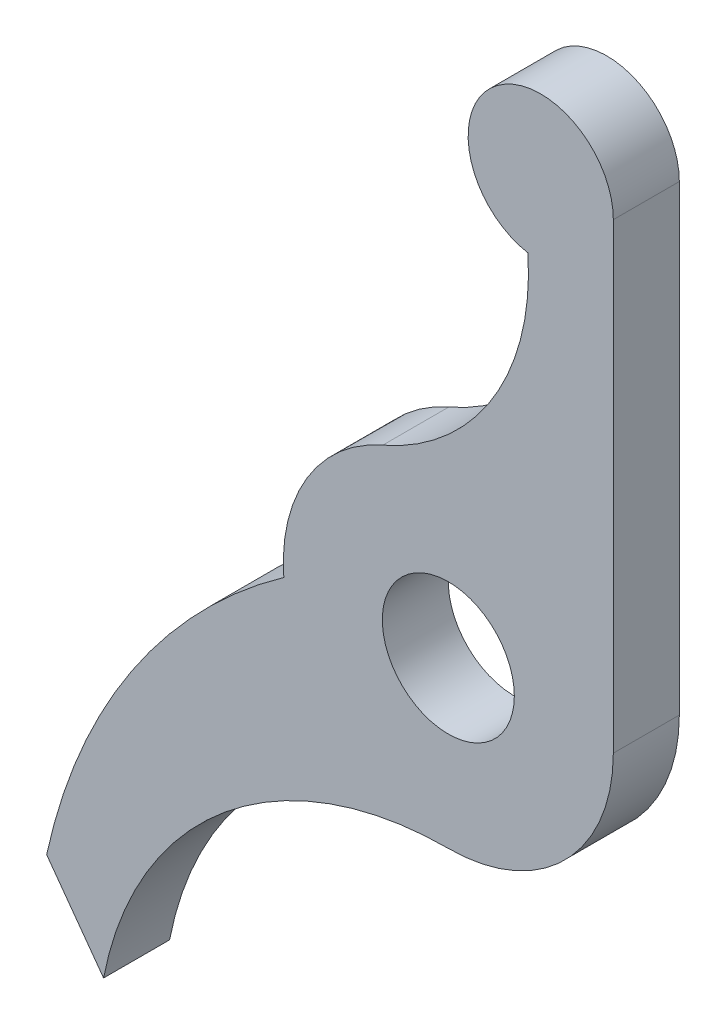
from build123d import *

# Parameters (mm, degrees)
BOSS_EXTRUDE1_DEPTH = 2
SKETCH3_R           = 2
CUT_EXTRUDE1_DEPTH  = 3


with BuildPart() as part:
    # Sketch2 → Boss-Extrude1 (new body)
    with BuildSketch(Plane.XY):
        with BuildLine():
            Line((-10.445641875, -94.122807376), (-12.17064978, -91.748537682))
            ThreePointArc((-12.17064978, -91.748537682), (-9.595543925, -85.642489446), (-4.985379129, -80.882092847))
            ThreePointArc((-4.985379129, -80.882092847), (-4.281750191, -77.918021049), (-1.988595944, -75.912464041))
            ThreePointArc((-1.988595944, -75.912464041), (1.364054662, -72.988805292), (2.410188275, -68.665189788))
            ThreePointArc((2.410188275, -68.665189788), (1.388898621, -64.812163249), (5, -66.5))
            Line((5, -66.5), (5, -80.5))
            ThreePointArc((5, -80.5), (3.535533906, -84.035533906), (0, -85.5))
            ThreePointArc((0, -85.5), (-6.77244862, -87.934189562), (-10.445641875, -94.122807376))
        make_face()
    extrude(amount=-BOSS_EXTRUDE1_DEPTH)

    # Sketch3 → Cut-Extrude1 (cut, through all)
    with BuildSketch(Plane.XY):
        with Locations((0, -80.5)):
            Circle(SKETCH3_R)
    extrude(amount=-CUT_EXTRUDE1_DEPTH, mode=Mode.SUBTRACT)


solid = part.part
